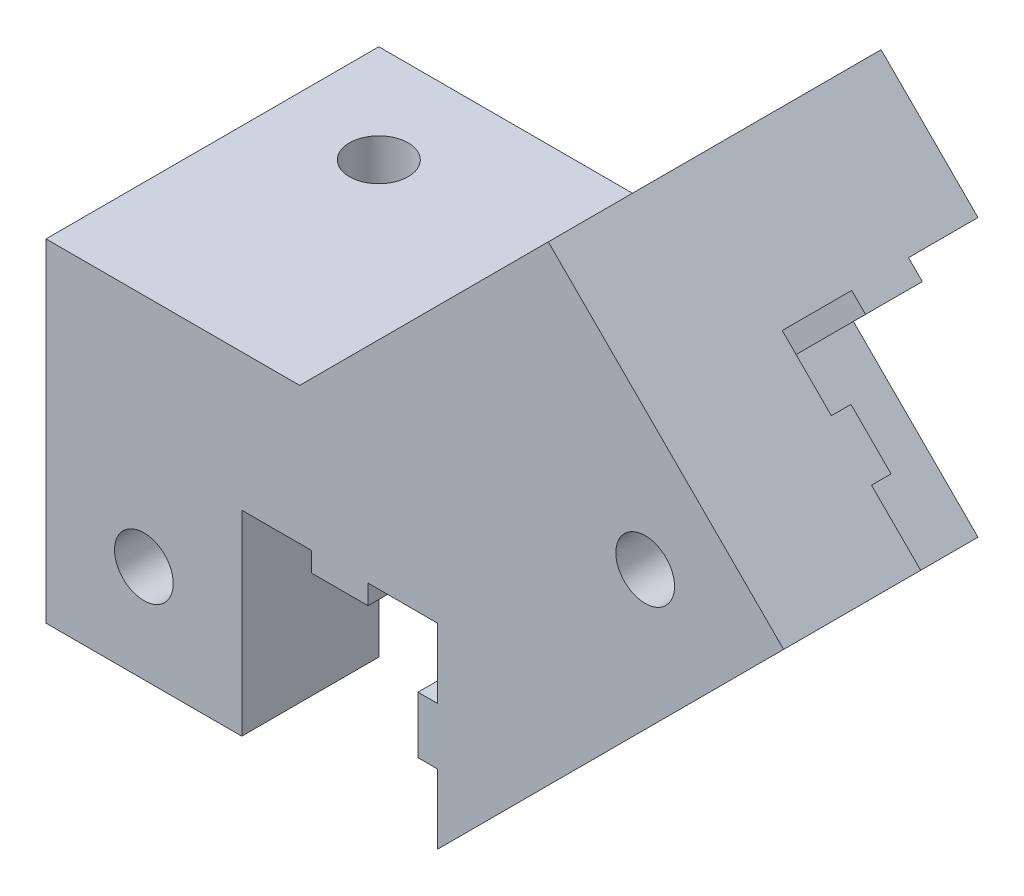
from build123d import *

# Parameters (mm, degrees)
MAIN_DEPTH          = 17
CUT_EXTRUDE1_DEPTH  = 10
SKETCH3_R           = 1.5
CUT_EXTRUDE2_DEPTH  = 18
SKETCH4_W           = 2.9
SKETCH4_H           = 1
SKETCH4_W_2         = 1
SKETCH4_H_2         = 2.9
BOSS_EXTRUDE1_DEPTH = 7
SKETCH5_W           = 15
SKETCH5_H           = 2.9
BOSS_EXTRUDE2_DEPTH = 1
SKETCH6_R           = 1.5
CUT_EXTRUDE3_DEPTH  = 18
BOSS_EXTRUDE3_DEPTH = 10
SKETCH8_R           = 1.5
CUT_EXTRUDE4_DEPTH  = 18
SKETCH9_R           = 1.5
CUT_EXTRUDE5_DEPTH  = 18.67766953


with BuildPart() as part:
    # Sketch1 → Main (new body)
    with BuildSketch(Plane.XY):
        Polygon((-90, -90), (-72.32233047, -72.32233047), (-84.343145751, -60.30151519), (-97.04163056, -73), (-110, -73), (-110, -80), (-90, -80), align=None)
    extrude(amount=MAIN_DEPTH)

    # Sketch2 → Cut-Extrude1 (cut)
    with BuildSketch(Plane(origin=(-72.32233047, -72.32233047, 0), x_dir=(0.707106781, -0.707106781, 0), z_dir=(0.707106781, 0.707106781, 0))):
        Polygon((-3.55, -10), (0, -10), (0, 0), (-10, 0), (-10, -3.55), (-9, -3.55), (-9, -6.45), (-10, -6.45), (-10, -10), (-6.45, -10), (-6.45, -9), (-3.55, -9), align=None)
    extrude(amount=-CUT_EXTRUDE1_DEPTH, mode=Mode.SUBTRACT)

    # Sketch3 → Cut-Extrude2 (cut, through all)
    with BuildSketch(Plane.XY.offset(17)):
        with Locations((-79.393398282, -72.32233047)):
            Circle(SKETCH3_R)
    extrude(amount=-CUT_EXTRUDE2_DEPTH, mode=Mode.SUBTRACT)

    # Sketch4 → Boss-Extrude1 (add)
    with BuildSketch(Plane.XY.offset(10)):
        with Locations((-95, -80.5)):
            Rectangle(SKETCH4_W, SKETCH4_H)
        with Locations((-90.5, -85)):
            Rectangle(SKETCH4_W_2, SKETCH4_H_2)
    extrude(amount=BOSS_EXTRUDE1_DEPTH)

    # Sketch5 → Boss-Extrude2 (add)
    with BuildSketch(Plane.XZ.offset(80)):
        with Locations((-102.5, 5)):
            Rectangle(SKETCH5_W, SKETCH5_H)
    extrude(amount=BOSS_EXTRUDE2_DEPTH)

    # Sketch6 → Cut-Extrude3 (cut, through all)
    with BuildSketch(Plane(origin=(0, -73, 0), x_dir=(1, 0, 0), z_dir=(0, 1, 0))):
        with Locations((-105, -5)):
            Circle(SKETCH6_R)
    extrude(amount=-CUT_EXTRUDE3_DEPTH, mode=Mode.SUBTRACT)

    # Sketch7 → Boss-Extrude3 (add)
    with BuildSketch(Plane.ZY.offset(110)):
        Polygon((17, -80), (17, -90), (10, -90), (10, -86.45), (9, -86.45), (9, -83.55), (10, -83.55), (10, -80), align=None)
    extrude(amount=-BOSS_EXTRUDE3_DEPTH)

    # Sketch8 → Cut-Extrude4 (cut, through all)
    with BuildSketch(Plane.XY.offset(17)):
        with Locations((-105, -85)):
            Circle(SKETCH8_R)
    extrude(amount=-CUT_EXTRUDE4_DEPTH, mode=Mode.SUBTRACT)

    # Sketch9 → Cut-Extrude5 (cut, through all)
    with BuildSketch(Plane.ZY.offset(90)):
        with Locations((5, -85)):
            Circle(SKETCH9_R)
    extrude(amount=-CUT_EXTRUDE5_DEPTH, mode=Mode.SUBTRACT)


solid = part.part
